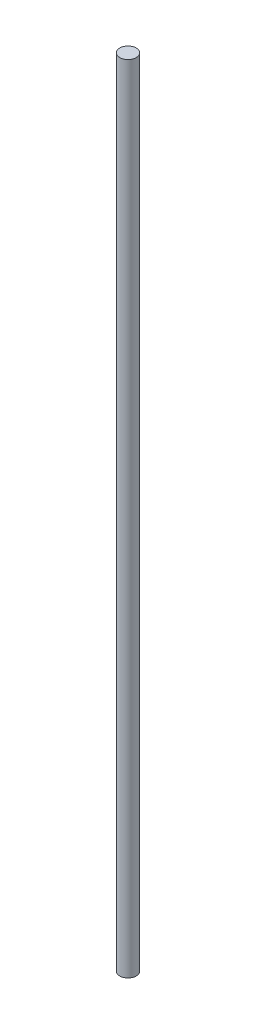
from build123d import *

# Parameters (mm, degrees)
SKETCH1_R           = 6.35
BOSS_EXTRUDE1_DEPTH = 304.8


with BuildPart() as part:
    # Sketch1 → Boss-Extrude1 (new body, symmetric)
    with BuildSketch(Plane(origin=(0, 0, 0), x_dir=(1, 0, 0), z_dir=(0, 1, 0))):
        Circle(SKETCH1_R)
    extrude(amount=BOSS_EXTRUDE1_DEPTH, both=True)


solid = part.part
